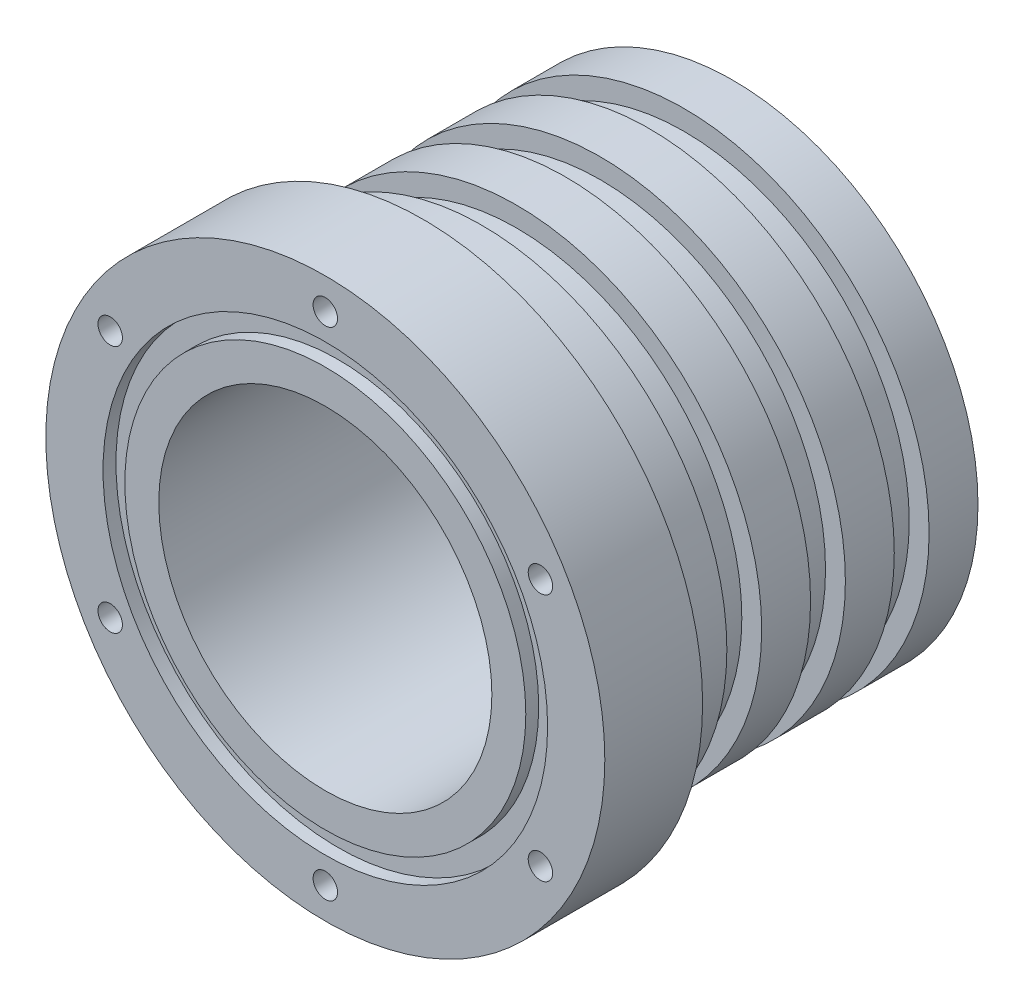
from build123d import *

# Parameters (mm, degrees)
M3X0_5_TAPPED_HOLE1_D     = 2.5
M3X0_5_TAPPED_HOLE1_DEPTH = 10
SKETCH5_R                 = 22.73
SKETCH5_R_2               = 20.5
CUT_EXTRUDE1_DEPTH        = 1.32


with BuildPart() as part:
    # Sketch1 → Revolve1 (revolve)
    with BuildSketch(Plane(origin=(0, 0, 0), x_dir=(1, 0, 0), z_dir=(0, 1, 0))):
        Polygon((-28.58, 0), (-28.58, 10), (-25.06, 10), (-25.06, 16), (-23.03, 16), (-23.03, 19.56), (-25.06, 19.56), (-25.06, 24.56), (-23.03, 24.56), (-23.03, 28.12), (-25.06, 28.12), (-25.06, 33.12), (-23.03, 33.12), (-23.03, 36.68), (-25.06, 36.68), (-25.06, 41.68), (-17.03, 41.68), (-17.03, 0), align=None)
    revolve(axis=Axis((0, 0, 0), (0, 0, -1)))

    # M3x0.5 Tapped Hole1
    with Locations(Plane.XY):
        with Locations((0, 25.4), (21.997045256, 12.7), (21.997045256, -12.7), (0, -25.4), (-21.997045256, -12.7), (-21.997045256, 12.7)):
            Hole(M3X0_5_TAPPED_HOLE1_D / 2, depth=M3X0_5_TAPPED_HOLE1_DEPTH)

    # Sketch5 → Cut-Extrude1 (cut)
    with BuildSketch(Plane.XY):
        Circle(SKETCH5_R)
        Circle(SKETCH5_R_2, mode=Mode.SUBTRACT)
    extrude(amount=-CUT_EXTRUDE1_DEPTH, mode=Mode.SUBTRACT)


solid = part.part
